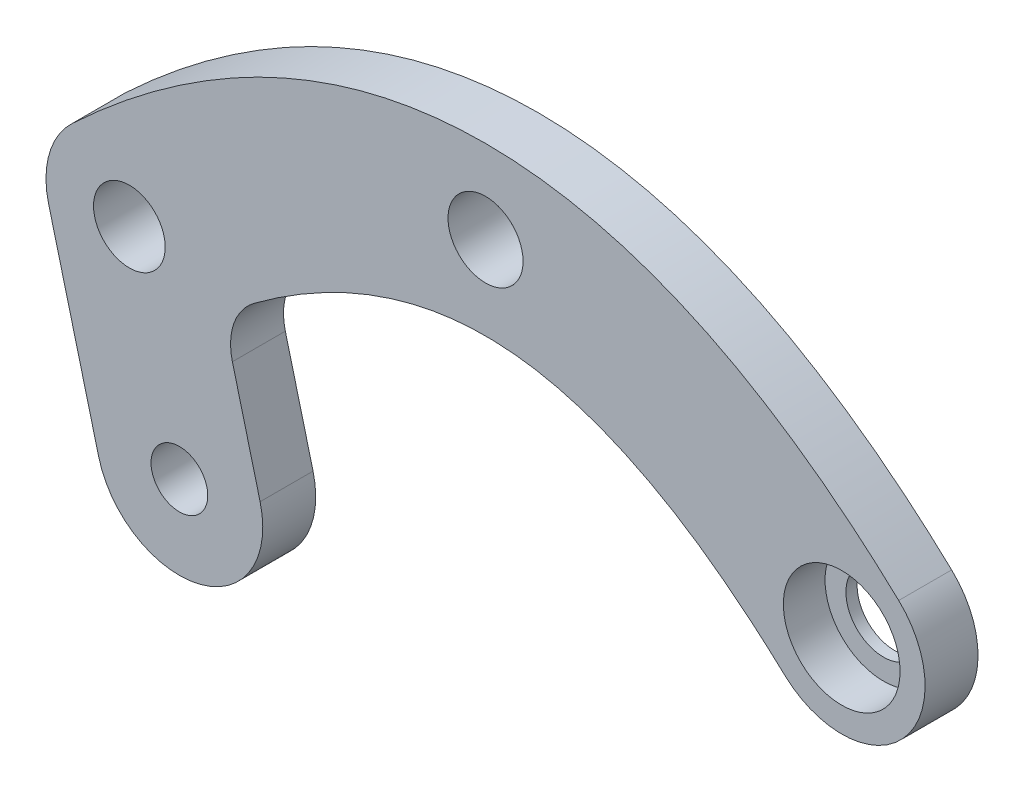
from build123d import *

# Parameters (mm, degrees)
BOSS_EXTRUDE1_DEPTH  = 1.5875
M4_CLEARANCE_HOLE1_D = 4.5
BOSS_EXTRUDE2_DEPTH  = 3.175
FILLET1_R            = 3.5
M3_CLEARANCE_HOLE1_D = 3.4
SKETCH8_R            = 2.15
CUT_EXTRUDE1_DEPTH   = 4.1750001
SKETCH9_R            = 2.75
SKETCH9_R_2          = 2.15
BOSS_EXTRUDE3_DEPTH  = 0.75
SKETCH10_R           = 3.5
CUT_EXTRUDE2_DEPTH   = 2.5


with BuildPart() as part:
    # Sketch2 → Boss-Extrude1 (new body, symmetric)
    with BuildSketch(Plane.XY):
        with BuildLine():
            ThreePointArc((-17.942568571, -13.649816766), (-25.009816766, -13.417431429), (-24.777431429, -6.350183234))
            add(Edge.make_bspline(
                [(-24.777431429, -6.350183234), (-20.441430485, -2.271315687), (-12.829947979, 2.196277878), (-6.501150321, 4.42663028), (0, 5.19112324), (6.501150321, 4.42663028), (12.829947979, 2.196277878), (20.441430485, -2.271315687), (24.777431429, -6.350183234)],
                knots=[0, 0, 0, 0.1875, 0.3125, 0.4375, 0.5625, 0.6875, 0.8125, 1, 1, 1], degree=2))
            ThreePointArc((24.777431429, -6.350183234), (25.009816766, -13.417431429), (17.942568571, -13.649816766))
            add(Edge.make_bspline(
                [(-17.942568571, -13.649816766), (-14.268569515, -10.228684313), (-8.530052021, -6.883777878), (-4.178849679, -5.36413028), (0, -4.87862324), (4.178849679, -5.36413028), (8.530052021, -6.883777878), (14.268569515, -10.228684313), (17.942568571, -13.649816766)],
                knots=[0, 0, 0, 0.1875, 0.3125, 0.4375, 0.5625, 0.6875, 0.8125, 1, 1, 1], degree=2))
        make_face()
    extrude(amount=BOSS_EXTRUDE1_DEPTH, both=True)

    # M4 Clearance Hole1 (through all)
    with Locations(Plane.XY.offset(1.5875)):
        with Locations((21.36, -10), (0, 0)):
            Hole(M4_CLEARANCE_HOLE1_D / 2)

    # Sketch5 → Boss-Extrude2 (add)
    with BuildSketch(Plane(origin=(0, 0, -1.5875), x_dir=(-1, 0, 0), z_dir=(0, 0, -1))):
        with BuildLine():
            ThreePointArc((13.518770817, -20.368950039), (17.11, -26.460179221), (23.201229183, -22.868950039))
            Line((23.201229183, -22.868950039), (26.201229183, -11.25))
            ThreePointArc((26.201229183, -11.25), (22.61, -5.158770817), (16.518770817, -8.75))
            Line((16.518770817, -8.75), (13.518770817, -20.368950039))
        make_face()
    extrude(amount=-BOSS_EXTRUDE2_DEPTH)

    # Fillet1
    fillet1_edges = [part.edges().sort_by_distance(p)[0] for p in [
        (-15.752223744, -11.718824048, 0.7937488),
    ]]
    fillet(fillet1_edges, radius=FILLET1_R)

    # M3 Clearance Hole1 (through all)
    with Locations(Plane(origin=(0, 0, -1.5875), x_dir=(-1, 0, 0), z_dir=(0, 0, -1))):
        with Locations((18.36, -21.618950039)):
            Hole(M3_CLEARANCE_HOLE1_D / 2)

    # Sketch8 → Cut-Extrude1 (cut, through all)
    with BuildSketch(Plane(origin=(0, 0, -1.5875), x_dir=(-1, 0, 0), z_dir=(0, 0, -1))):
        with Locations((21.36, -10)):
            Circle(SKETCH8_R)
    extrude(amount=-CUT_EXTRUDE1_DEPTH, mode=Mode.SUBTRACT)

    # Sketch9 → Boss-Extrude3 (add)
    with BuildSketch(Plane(origin=(0, 0, -1.5875), x_dir=(-1, 0, 0), z_dir=(0, 0, -1))):
        with Locations((21.36, -10)):
            Circle(SKETCH9_R)
        with Locations((21.36, -10)):
            Circle(SKETCH9_R_2, mode=Mode.SUBTRACT)
    extrude(amount=BOSS_EXTRUDE3_DEPTH)

    # Sketch10 → Cut-Extrude2 (cut)
    with BuildSketch(Plane.XY.offset(1.5875)):
        with Locations((21.36, -10)):
            Circle(SKETCH10_R)
    extrude(amount=-CUT_EXTRUDE2_DEPTH, mode=Mode.SUBTRACT)


solid = part.part
